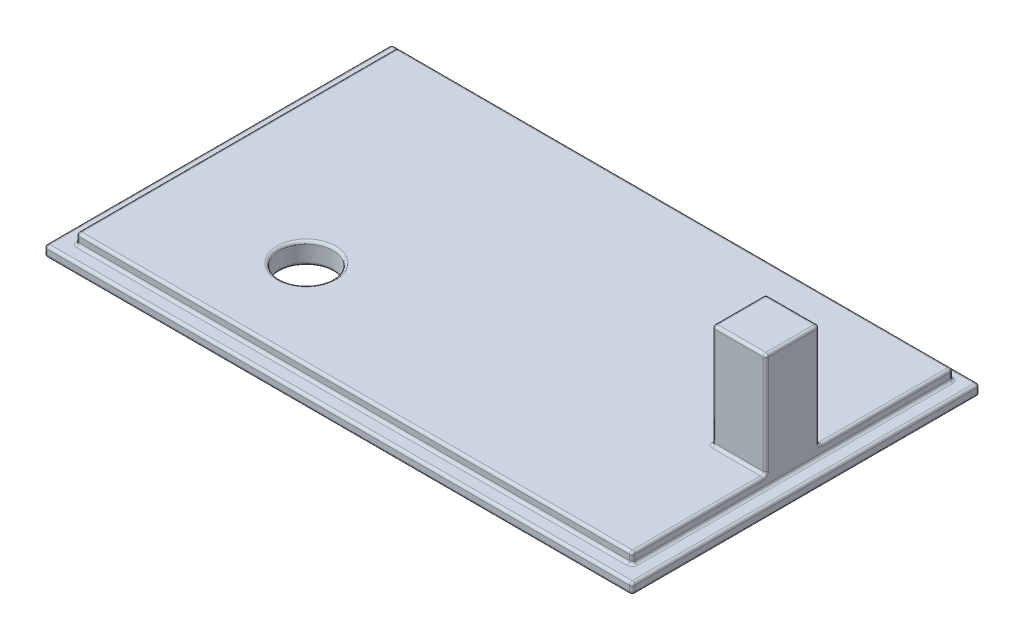
from build123d import *

# Parameters (mm, degrees)
SKETCH1_W           = 110
SKETCH1_H           = 65
BOSS_EXTRUDE1_DEPTH = 2
SKETCH2_W           = 104
SKETCH2_H           = 60
BOSS_EXTRUDE3_DEPTH = 2
SKETCH6_W           = 10
SKETCH6_H           = 10
BOSS_EXTRUDE4_DEPTH = 19.5
SKETCH7_R           = 5
CUT_EXTRUDE1_DEPTH  = 5
FILLET1_R           = 0.5


with BuildPart() as part:
    # Sketch1 → Boss-Extrude1 (new body)
    with BuildSketch(Plane(origin=(0, 0, 0), x_dir=(1, 0, 0), z_dir=(0, 1, 0))):
        with Locations((-2.954873439, 1.833455829)):
            Rectangle(SKETCH1_W, SKETCH1_H)
    extrude(amount=BOSS_EXTRUDE1_DEPTH)

    # Sketch2 → Boss-Extrude3 (add)
    with BuildSketch(Plane(origin=(0, 2, 0), x_dir=(1, 0, 0), z_dir=(0, 1, 0))):
        with Locations((-2.954873439, 2.333455829)):
            Rectangle(SKETCH2_W, SKETCH2_H)
    extrude(amount=BOSS_EXTRUDE3_DEPTH)

    # Sketch6 → Boss-Extrude4 (add)
    with BuildSketch(Plane(origin=(0, 4, 0), x_dir=(1, 0, 0), z_dir=(0, 1, 0))):
        with Locations((44.045126561, 2.333455829)):
            Rectangle(SKETCH6_W, SKETCH6_H)
    extrude(amount=BOSS_EXTRUDE4_DEPTH)

    # Sketch7 → Cut-Extrude1 (cut, through all)
    with BuildSketch(Plane(origin=(0, 4, 0), x_dir=(1, 0, 0), z_dir=(0, 1, 0))):
        with Locations((-28.454873439, -11.166544171)):
            Circle(SKETCH7_R)
    extrude(amount=-CUT_EXTRUDE1_DEPTH, mode=Mode.SUBTRACT)

    # Fillet1
    fillet1_edges = [part.edges().sort_by_distance(p)[0] for p in [
        (52.045126561, 2, -1.833455829),
        (-2.954873439, 2, -34.333455829),
        (-2.954873439, 4, -32.333455829),
        (49.045126561, 3, -32.333455829),
        (-54.954873439, 2, -2.333455829),
        (-54.954873439, 3, -32.333455829),
        (-2.954873439, 2, 27.666544171),
        (-54.954873439, 3, 27.666544171),
        (49.045126561, 4, -19.833455829),
        (49.045126561, 3, 27.666544171),
        (-54.954873439, 4, -2.333455829),
        (-2.954873439, 4, 27.666544171),
        (-2.954873439, 2, -32.333455829),
        (49.045126561, 2, -2.333455829),
        (49.045126561, 4, 15.166544171),
        (49.045126561, 23.5, -2.333455829),
        (49.045126561, 13.75, 2.666544171),
        (44.045126561, 4, -7.333455829),
        (49.045126561, 13.75, -7.333455829),
        (39.045126561, 4, -2.333455829),
        (39.045126561, 13.75, -7.333455829),
        (44.045126561, 23.5, 2.666544171),
        (39.045126561, 13.75, 2.666544171),
        (44.045126561, 23.5, -7.333455829),
        (39.045126561, 23.5, -2.333455829),
        (44.045126561, 4, 2.666544171),
        (-57.954873439, 2, -1.833455829),
        (-33.454873439, 0, 11.166544171),
        (-33.454873439, 4, 11.166544171),
        (-2.954873439, 0, -34.333455829),
        (52.045126561, 0, -1.833455829),
        (-2.954873439, 0, 30.666544171),
        (-57.954873439, 0, -1.833455829),
        (-2.954873439, 2, 30.666544171),
        (-57.954873439, 1, -34.333455829),
        (52.045126561, 1, -34.333455829),
        (52.045126561, 1, 30.666544171),
        (-57.954873439, 1, 30.666544171),
    ]]
    fillet(fillet1_edges, radius=FILLET1_R)


solid = part.part
